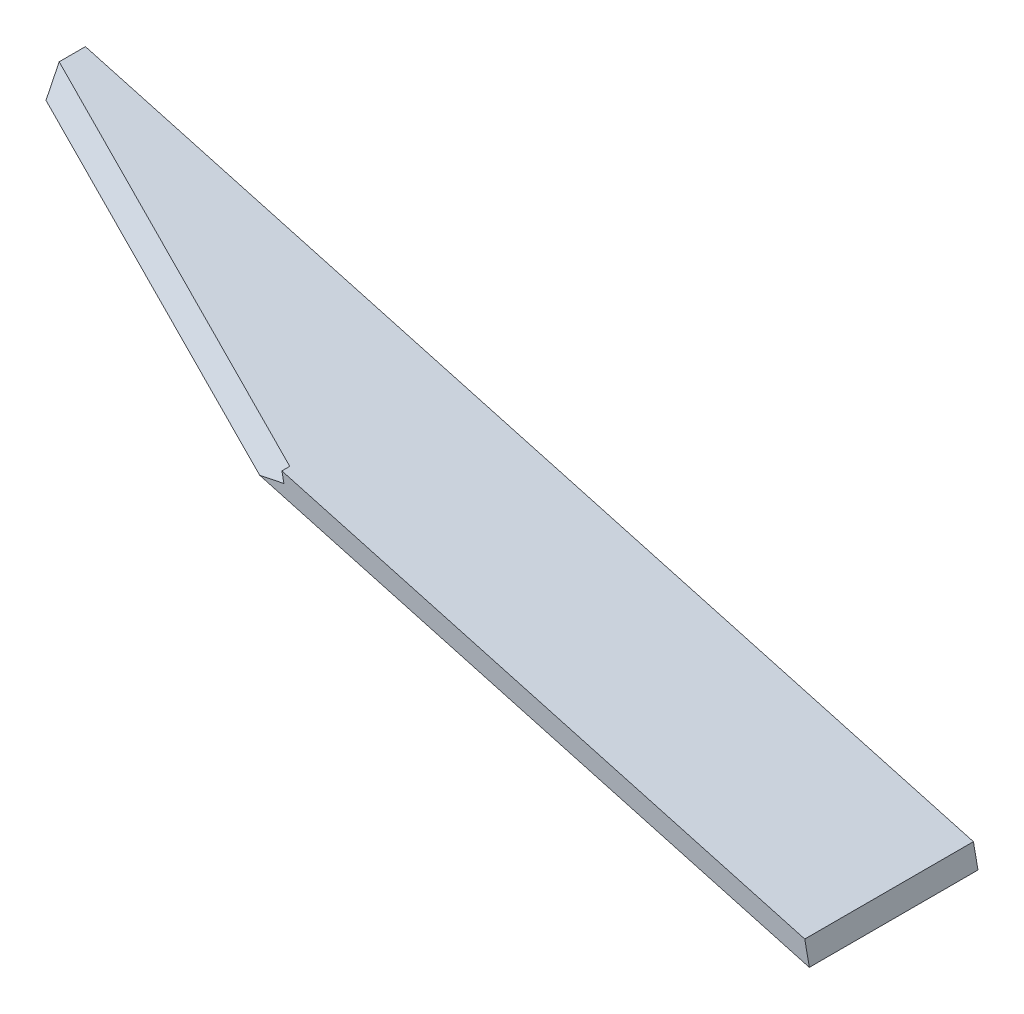
from build123d import *

# Parameters (mm, degrees)
BOSS_EXTRUDE3_DEPTH = 25
CUT_EXTRUDE1_DEPTH  = 17.63474099


with BuildPart() as part:
    # Sketch6 → Boss-Extrude3 (new body)
    with BuildSketch(Plane.XY):
        Polygon((-76.7010904, 15.884310045), (-77.381092708, 19.183202304), (-209.008603901, 55.427262562), (-208.328601592, 52.128370303), align=None)
    extrude(amount=BOSS_EXTRUDE3_DEPTH)

    # Sketch7 → Cut-Extrude1 (cut, through all)
    with BuildSketch(Plane(origin=(-7.764079932, 37.665847394, 49.223649712), x_dir=(0.992149154, 0.086592284, 0.090232106), z_dir=(-0.124293475, 0.602984398, 0.788010754))):
        Polygon((-196.71104708, 7.314103793), (-147.250967101, 14.642165505), (-153.953814385, 59.882418078), (-203.413894364, 52.554356365), align=None)
    extrude(amount=CUT_EXTRUDE1_DEPTH, mode=Mode.SUBTRACT)


solid = part.part
